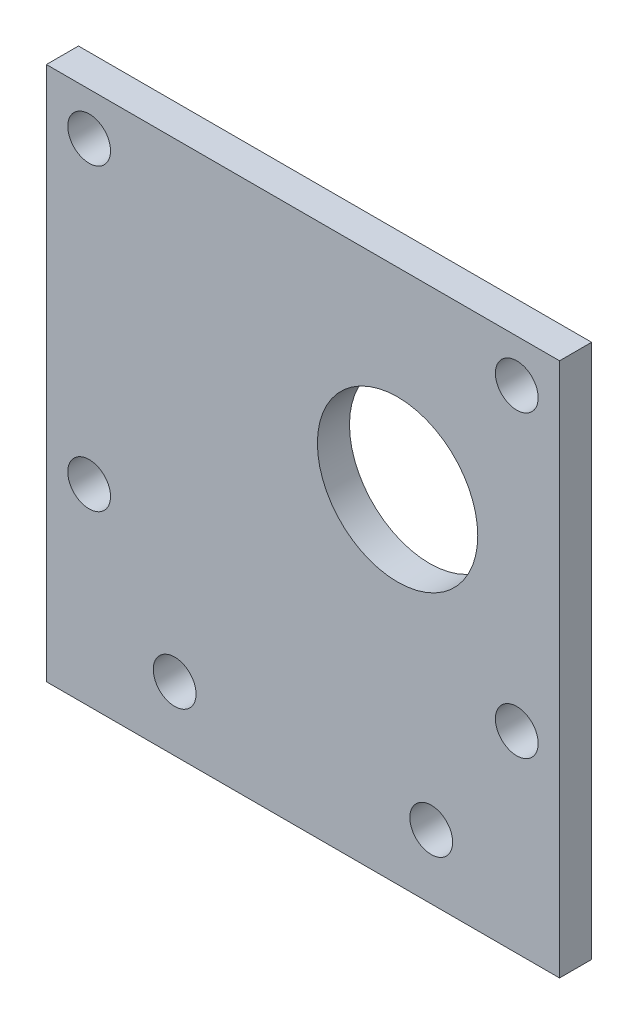
from build123d import *

# Parameters (mm, degrees)
SKETCH2_W           = 48
SKETCH2_H           = 50
SKETCH2_R           = 2
SKETCH2_R_2         = 7.5
BOSS_EXTRUDE2_DEPTH = 3


with BuildPart() as part:
    # Sketch2 → Boss-Extrude2 (new body)
    with BuildSketch(Plane.XY):
        with Locations((24, 25)):
            Rectangle(SKETCH2_W, SKETCH2_H)
        with Locations((4, 46)):
            Circle(SKETCH2_R, mode=Mode.SUBTRACT)
        with Locations((44, 46)):
            Circle(SKETCH2_R, mode=Mode.SUBTRACT)
        with Locations((44, 18)):
            Circle(SKETCH2_R, mode=Mode.SUBTRACT)
        with Locations((4, 18)):
            Circle(SKETCH2_R, mode=Mode.SUBTRACT)
        with Locations((32.85, 32)):
            Circle(SKETCH2_R_2, mode=Mode.SUBTRACT)
        with Locations((12, 6)):
            Circle(SKETCH2_R, mode=Mode.SUBTRACT)
        with Locations((36, 6)):
            Circle(SKETCH2_R, mode=Mode.SUBTRACT)
    extrude(amount=BOSS_EXTRUDE2_DEPTH)


solid = part.part
